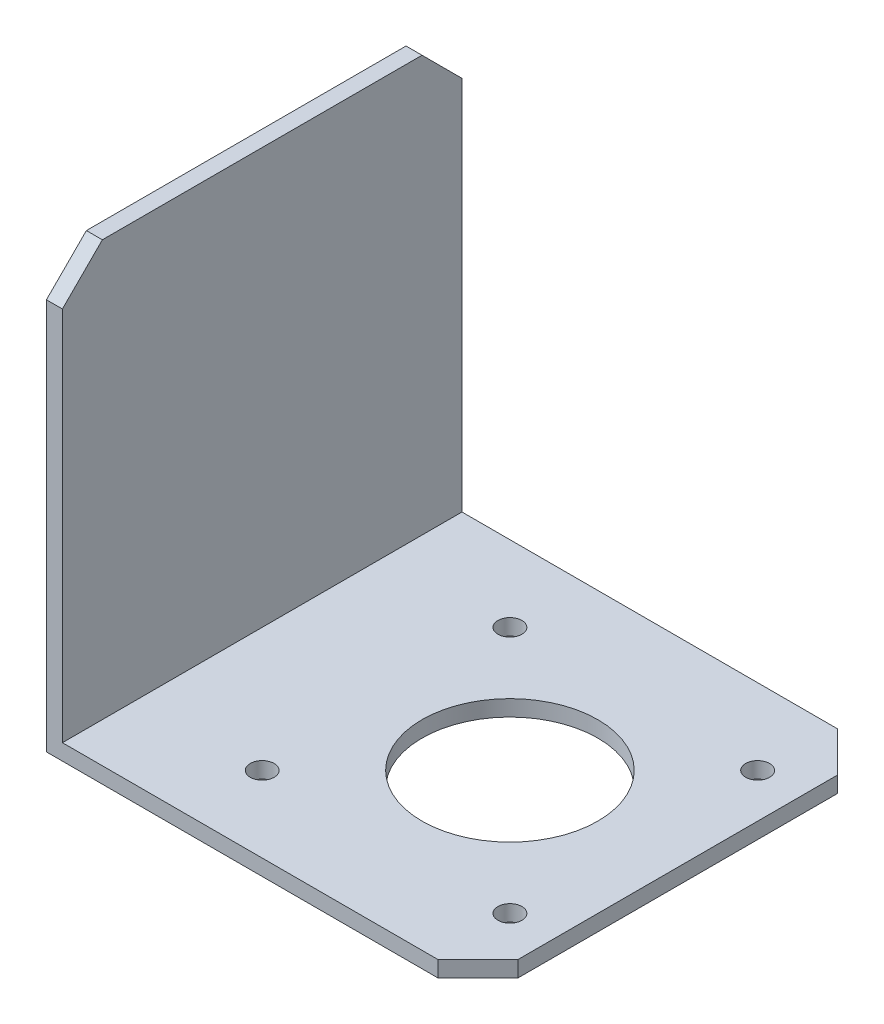
from build123d import *

# Parameters (mm, degrees)
EXTRUDE_THIN1_DEPTH = 50
CHAMFER1_SIZE       = 5
SKETCH2_R           = 11
SKETCH2_R_2         = 1.5
CUT_EXTRUDE1_DEPTH  = 10


with BuildPart() as part:
    # Sketch1 → Extrude-Thin1 (new body)
    with BuildSketch(Plane.XY):
        Polygon((52, 0), (0, 0), (0, 52), (-2, 52), (-2, -2), (52, -2), align=None)
    extrude(amount=EXTRUDE_THIN1_DEPTH)

    # Chamfer1
    chamfer1_edges = [part.edges().sort_by_distance(p)[0] for p in [
        (-1, 52, 50),
        (-1, 52, 0),
        (52, -1, 0),
        (52, -1, 50),
    ]]
    chamfer(chamfer1_edges, length=CHAMFER1_SIZE)

    # Sketch2 → Cut-Extrude1 (cut)
    with BuildSketch(Plane.XZ.offset(2)):
        with Locations((31, 25)):
            Circle(SKETCH2_R)
        with Locations((15.5, 40.5)):
            Circle(SKETCH2_R_2)
        with Locations((46.5, 40.5)):
            Circle(SKETCH2_R_2)
        with Locations((46.5, 9.5)):
            Circle(SKETCH2_R_2)
        with Locations((15.5, 9.5)):
            Circle(SKETCH2_R_2)
    extrude(amount=-CUT_EXTRUDE1_DEPTH, mode=Mode.SUBTRACT)


solid = part.part
